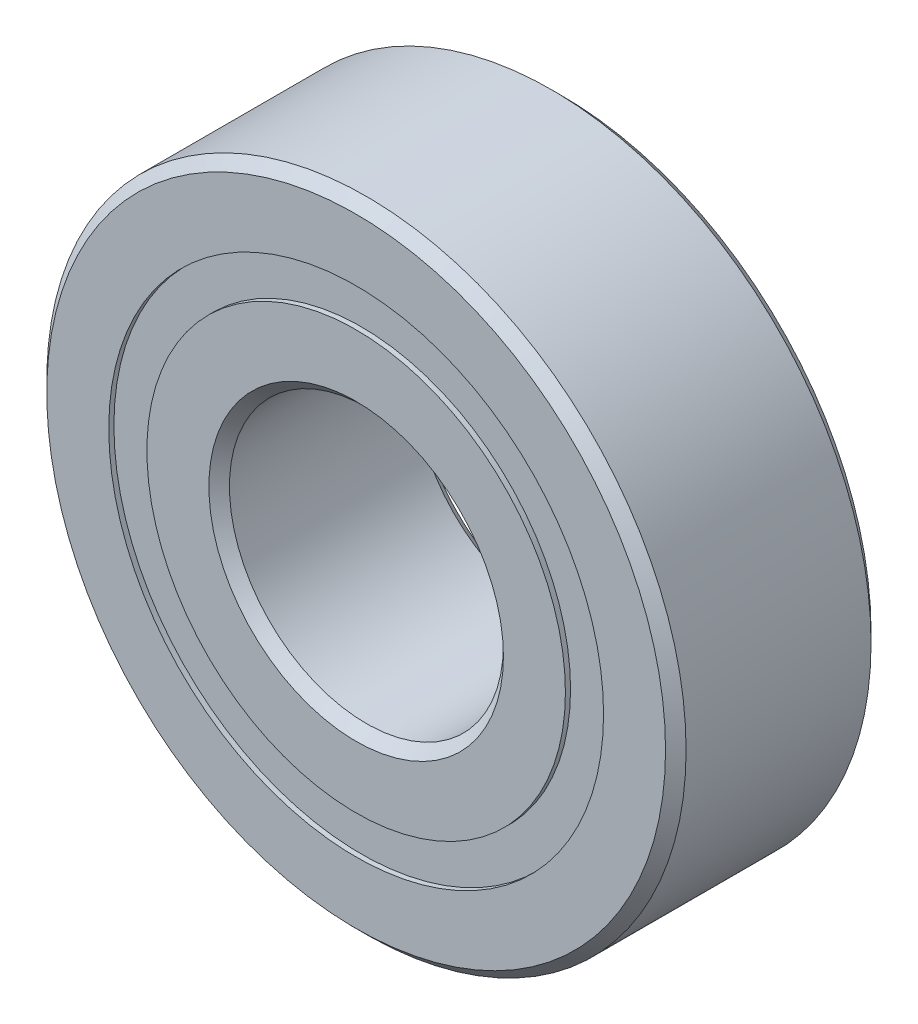
from build123d import *

# Parameters (mm, degrees)
CIRPATTERN1_COUNT = 12
SKETCH5_W         = 1.672929924
SKETCH5_H         = 1.325824176


with BuildPart() as part:
    # Sketch1 → Revolve1 (revolve)
    with BuildSketch(Plane(origin=(0, 0, 0), x_dir=(0, 0, -1), z_dir=(1, 0, 0)), mode=Mode.PRIVATE) as revolve1_sk:
        with BuildLine():
            Line((3.2146875, 11.1125), (-3.2146875, 11.1125))
            Line((-3.2146875, 11.1125), (-3.571875, 10.7553125))
            Line((-3.571875, 10.7553125), (-3.571875, 8.600412088))
            Line((-3.571875, 8.600412088), (-1.5875, 8.600412088))
            ThreePointArc((-1.5875, 8.600412088), (0, 9.657851326), (1.5875, 8.600412088))
            Line((1.5875, 8.600412088), (3.571875, 8.600412088))
            Line((3.571875, 8.600412088), (3.571875, 10.7553125))
            Line((3.571875, 10.7553125), (3.2146875, 11.1125))
        make_face()
    revolve(revolve1_sk.sketch.rotate(Axis((0, 0, 3.571875), (0, 0, -1)), 90), axis=Axis((0, 0, 3.571875), (0, 0, -1)))  # turned: the seam where the file's is


with BuildPart() as body_2:
    # Sketch3 → Revolve3 (revolve)
    with BuildSketch(Plane(origin=(0, 0, 0), x_dir=(0, 0, -1), z_dir=(1, 0, 0)), mode=Mode.PRIVATE) as revolve3_sk:
        with BuildLine():
            Line((-3.571875, 7.274587912), (-1.5875, 7.274587912))
            ThreePointArc((-1.5875, 7.274587912), (0, 6.217148674), (1.5875, 7.274587912))
            Line((1.5875, 7.274587912), (3.571875, 7.274587912))
            Line((3.571875, 7.274587912), (3.571875, 5.1196875))
            Line((3.571875, 5.1196875), (3.2146875, 4.7625))
            Line((3.2146875, 4.7625), (-3.2146875, 4.7625))
            Line((-3.2146875, 4.7625), (-3.571875, 5.1196875))
            Line((-3.571875, 5.1196875), (-3.571875, 7.274587912))
        make_face()
    revolve(revolve3_sk.sketch.rotate(Axis((0, 0, 3.571875), (0, 0, -1)), 90), axis=Axis((0, 0, 3.571875), (0, 0, -1)))  # turned: the seam where the file's is


with BuildPart() as body_3:
    # Sketch4 → Revolve4 (revolve)
    with BuildSketch(Plane(origin=(0, 0, 0), x_dir=(0, 0, -1), z_dir=(1, 0, 0))):
        with BuildLine():
            Line((-1.720351326, 7.9375), (1.720351326, 7.9375))
            ThreePointArc((1.720351326, 7.9375), (0, 9.657851326), (-1.720351326, 7.9375))
        make_face()
    revolve(axis=Axis((0, 7.9375, 1.720351326), (0, 0, -1)))


with BuildPart() as cirpattern1_1:
    # CirPattern1: pattern copy
    add(body_3.part.rotate(Axis((0, 0, 0), (0, 0, 1)), 1 * 360 / CIRPATTERN1_COUNT))


with BuildPart() as cirpattern1_2:
    # CirPattern1: pattern copy
    add(body_3.part.rotate(Axis((0, 0, 0), (0, 0, 1)), 2 * 360 / CIRPATTERN1_COUNT))


with BuildPart() as cirpattern1_3:
    # CirPattern1: pattern copy
    add(body_3.part.rotate(Axis((0, 0, 0), (0, 0, 1)), 3 * 360 / CIRPATTERN1_COUNT))


with BuildPart() as cirpattern1_4:
    # CirPattern1: pattern copy
    add(body_3.part.rotate(Axis((0, 0, 0), (0, 0, 1)), 4 * 360 / CIRPATTERN1_COUNT))


with BuildPart() as cirpattern1_5:
    # CirPattern1: pattern copy
    add(body_3.part.rotate(Axis((0, 0, 0), (0, 0, 1)), 5 * 360 / CIRPATTERN1_COUNT))


with BuildPart() as cirpattern1_6:
    # CirPattern1: pattern copy
    add(body_3.part.rotate(Axis((0, 0, 0), (0, 0, 1)), 6 * 360 / CIRPATTERN1_COUNT))


with BuildPart() as cirpattern1_7:
    # CirPattern1: pattern copy
    add(body_3.part.rotate(Axis((0, 0, 0), (0, 0, 1)), 7 * 360 / CIRPATTERN1_COUNT))


with BuildPart() as cirpattern1_8:
    # CirPattern1: pattern copy
    add(body_3.part.rotate(Axis((0, 0, 0), (0, 0, 1)), 8 * 360 / CIRPATTERN1_COUNT))


with BuildPart() as cirpattern1_9:
    # CirPattern1: pattern copy
    add(body_3.part.rotate(Axis((0, 0, 0), (0, 0, 1)), 9 * 360 / CIRPATTERN1_COUNT))


with BuildPart() as cirpattern1_10:
    # CirPattern1: pattern copy
    add(body_3.part.rotate(Axis((0, 0, 0), (0, 0, 1)), 10 * 360 / CIRPATTERN1_COUNT))


with BuildPart() as cirpattern1_11:
    # CirPattern1: pattern copy
    add(body_3.part.rotate(Axis((0, 0, 0), (0, 0, 1)), 11 * 360 / CIRPATTERN1_COUNT))


with BuildPart() as body_15:
    # Sketch5 → Revolve5 (revolve)
    with BuildSketch(Plane(origin=(0, 0, 0), x_dir=(0, 0, -1), z_dir=(1, 0, 0)), mode=Mode.PRIVATE) as revolve5_sk:
        with Locations((-2.556816288, 7.9375)):
            Rectangle(SKETCH5_W, SKETCH5_H)
        with Locations((2.556816288, 7.9375)):
            Rectangle(SKETCH5_W, SKETCH5_H)
    revolve(revolve5_sk.sketch.rotate(Axis((0, 0, 3.571875), (0, 0, -1)), 90), axis=Axis((0, 0, 3.571875), (0, 0, -1)))  # turned: the seam where the file's is


solid = Compound([part.part, body_2.part, body_3.part, cirpattern1_1.part, cirpattern1_2.part, cirpattern1_3.part, cirpattern1_4.part, cirpattern1_5.part, cirpattern1_6.part, cirpattern1_7.part, cirpattern1_8.part, cirpattern1_9.part, cirpattern1_10.part, cirpattern1_11.part, body_15.part])
